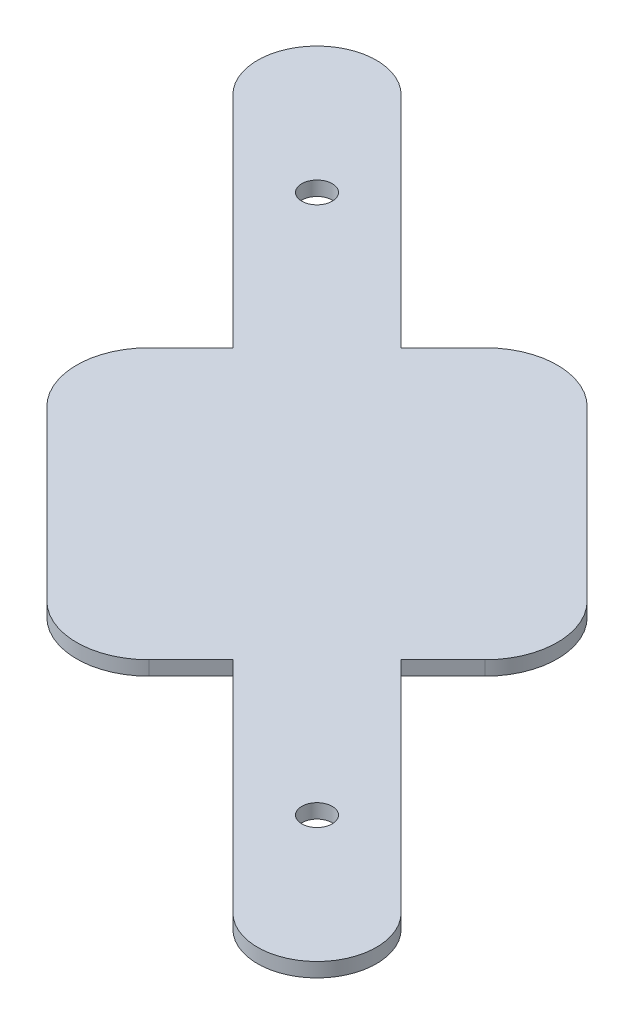
from build123d import *

# Parameters (mm, degrees)
SKETCH1_R           = 3.2
BOSS_EXTRUDE1_DEPTH = 3


with BuildPart() as part:
    # Sketch1 → Boss-Extrude1 (new body)
    with BuildSketch(Plane(origin=(0, 0, 0), x_dir=(1, 0, 0), z_dir=(0, 1, 0))):
        with BuildLine():
            Line((-46.074522422, 10.719183363), (-37.235687657, 19.558018127))
            Line((-37.235687657, 19.558018127), (-74.493699398, 56.816029868))
            Line((-74.493699398, 56.816029868), (-83.332534163, 65.654864633))
            ThreePointArc((-83.332534163, 65.654864633), (-83.332534163, 83.332534163), (-65.654864633, 83.332534163))
            Line((-65.654864633, 83.332534163), (-56.816029868, 74.493699398))
            Line((-56.816029868, 74.493699398), (-19.558018127, 37.235687657))
            Line((-19.558018127, 37.235687657), (-10.719183363, 46.074522422))
            ThreePointArc((-10.719183363, 46.074522422), (0, 50.514553548), (10.719183363, 46.074522422))
            Line((10.719183363, 46.074522422), (46.074522422, 10.719183363))
            ThreePointArc((46.074522422, 10.719183363), (50.514553548, 0), (46.074522422, -10.719183363))
            Line((46.074522422, -10.719183363), (37.235687657, -19.558018127))
            Line((37.235687657, -19.558018127), (74.493699398, -56.816029868))
            Line((74.493699398, -56.816029868), (83.332534163, -65.654864633))
            ThreePointArc((83.332534163, -65.654864633), (83.332534163, -83.332534163), (65.654864633, -83.332534163))
            Line((65.654864633, -83.332534163), (56.816029868, -74.493699398))
            Line((56.816029868, -74.493699398), (19.558018127, -37.235687657))
            Line((19.558018127, -37.235687657), (10.719183363, -46.074522422))
            ThreePointArc((10.719183363, -46.074522422), (0, -50.514553548), (-10.719183363, -46.074522422))
            Line((-10.719183363, -46.074522422), (-46.074522422, -10.719183363))
            ThreePointArc((-46.074522422, -10.719183363), (-50.514553548, 0), (-46.074522422, 10.719183363))
        make_face()
        with Locations((56.674608512, -56.674608512)):
            Circle(SKETCH1_R, mode=Mode.SUBTRACT)
        with Locations((-56.674608512, 56.674608512)):
            Circle(SKETCH1_R, mode=Mode.SUBTRACT)
    extrude(amount=BOSS_EXTRUDE1_DEPTH)


solid = part.part
